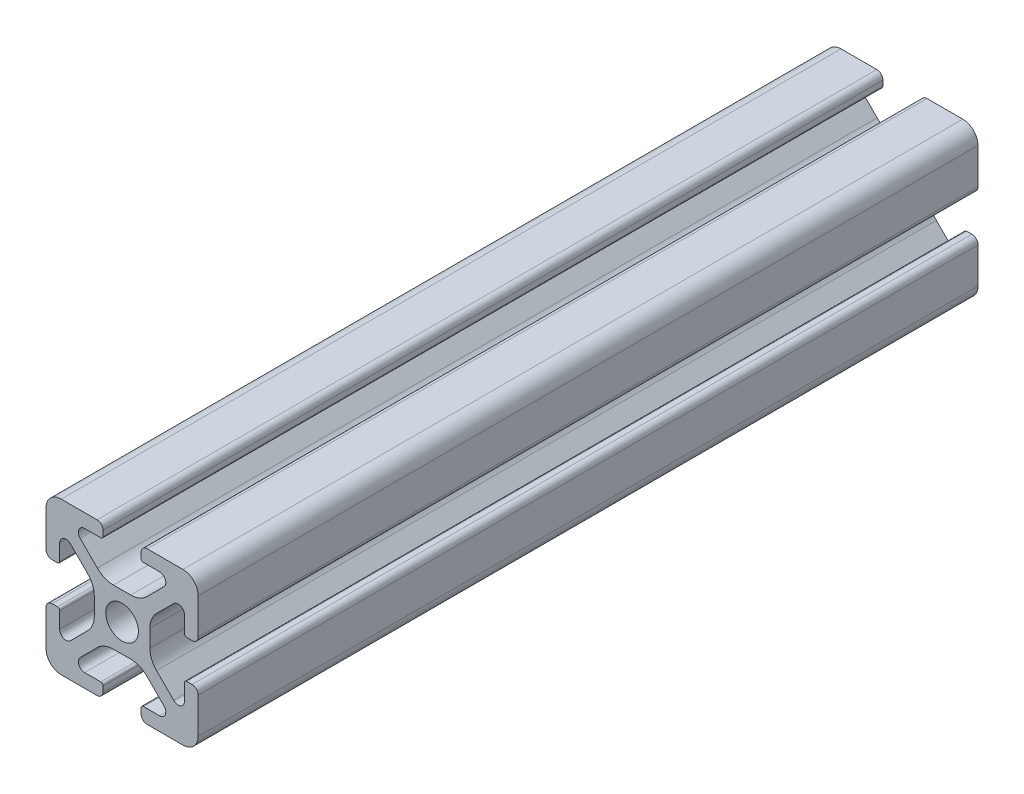
from build123d import *

# Parameters (mm, degrees)
SKIZZE1_R                       = 2.15
AUFSATZ_LINEAR_AUSTRAGEN1_DEPTH = 102.5


with BuildPart() as part:
    # Skizze1 → Aufsatz-Linear austragen1 (new body)
    with BuildSketch(Plane.XY.offset(100)):
        with BuildLine():
            Line((12.499999989, 1.499999999), (12.499999989, 0.800000002))
            ThreePointArc((12.499999989, 0.800000002), (12.734314564, 0.234314576), (13.299999991, 0))
            Line((13.299999991, 0), (18, 0))
            ThreePointArc((18, 0), (19.414213562, 0.585786438), (20, 2))
            Line((20, 2), (20, 6.700000003))
            ThreePointArc((20, 6.700000003), (19.765685425, 7.265685427), (19.2, 7.500000003))
            Line((19.2, 7.500000003), (18.499999995, 7.500000003))
            ThreePointArc((18.499999995, 7.500000003), (18.287867961, 7.412132037), (18.199999995, 7.200000003))
            Line((18.199999995, 7.200000003), (18.199999995, 5.082411607))
            ThreePointArc((18.199999995, 5.082411607), (17.686138517, 4.313363558), (16.778984491, 4.493807713))
            Line((16.778984491, 4.493807713), (14.528679651, 6.744112553))
            ThreePointArc((14.528679651, 6.744112553), (13.878361397, 7.717382599), (13.649999995, 8.865432896))
            Line((13.649999995, 8.865432896), (13.649999995, 11.134567106))
            ThreePointArc((13.649999995, 11.134567106), (13.878361397, 12.282617403), (14.528679651, 13.255887449))
            Line((14.528679651, 13.255887449), (16.778984493, 15.506192291))
            ThreePointArc((16.778984493, 15.506192291), (17.686138518, 15.686636446), (18.199999995, 14.917588398))
            Line((18.199999995, 14.917588398), (18.199999995, 12.800000001))
            ThreePointArc((18.199999995, 12.800000001), (18.287867961, 12.587867966), (18.499999996, 12.5))
            Line((18.499999996, 12.5), (19.199999998, 12.5))
            ThreePointArc((19.199999998, 12.5), (19.765685424, 12.734314576), (20, 13.300000003))
            Line((20, 13.300000003), (20, 18))
            ThreePointArc((20, 18), (19.414213562, 19.414213562), (18, 20))
            Line((18, 20), (13.299999989, 20))
            ThreePointArc((13.299999989, 20), (12.734314564, 19.765685425), (12.499999989, 19.2))
            Line((12.499999989, 19.2), (12.499999989, 18.499999999))
            ThreePointArc((12.499999989, 18.499999999), (12.587867954, 18.287867964), (12.799999989, 18.199999999))
            Line((12.799999989, 18.199999999), (14.917588395, 18.199999999))
            ThreePointArc((14.917588395, 18.199999999), (15.686636445, 17.68613852), (15.50619229, 16.778984493))
            Line((15.50619229, 16.778984493), (13.255887454, 14.528679658))
            ThreePointArc((13.255887454, 14.528679658), (12.282617408, 13.878361404), (11.134567111, 13.650000002))
            Line((11.134567111, 13.650000002), (8.865432888, 13.650000002))
            ThreePointArc((8.865432888, 13.650000002), (7.717382592, 13.878361404), (6.744112546, 14.528679658))
            Line((6.744112546, 14.528679658), (4.493807706, 16.778984498))
            ThreePointArc((4.493807706, 16.778984498), (4.313363551, 17.686138522), (5.082411599, 18.199999999))
            Line((5.082411599, 18.199999999), (7.199999999, 18.199999999))
            ThreePointArc((7.199999999, 18.199999999), (7.412132034, 18.287867965), (7.5, 18.5))
            Line((7.5, 18.5), (7.5, 19.199999998))
            ThreePointArc((7.5, 19.199999998), (7.265685424, 19.765685424), (6.699999997, 20))
            Line((6.699999997, 20), (2, 20))
            ThreePointArc((2, 20), (0.585786438, 19.414213562), (0, 18))
            Line((0, 18), (0, 13.3))
            ThreePointArc((0, 13.3), (0.234314575, 12.734314575), (0.8, 12.5))
            Line((0.8, 12.5), (1.500000004, 12.5))
            ThreePointArc((1.500000004, 12.5), (1.712132038, 12.587867966), (1.800000004, 12.8))
            Line((1.800000004, 12.8), (1.800000004, 14.917588391))
            ThreePointArc((1.800000004, 14.917588391), (2.313861482, 15.68663644), (3.221015508, 15.506192285))
            Line((3.221015508, 15.506192285), (5.471320345, 13.255887449))
            ThreePointArc((5.471320345, 13.255887449), (6.121638599, 12.282617402), (6.350000001, 11.134567106))
            Line((6.350000001, 11.134567106), (6.350000001, 8.865432891))
            ThreePointArc((6.350000001, 8.865432891), (6.121638599, 7.717382594), (5.471320345, 6.744112548))
            Line((5.471320345, 6.744112548), (3.221015505, 4.493807708))
            ThreePointArc((3.221015505, 4.493807708), (2.313861481, 4.313363554), (1.800000004, 5.082411601))
            Line((1.800000004, 5.082411601), (1.800000004, 7.200000001))
            ThreePointArc((1.800000004, 7.200000001), (1.712132038, 7.412132036), (1.500000003, 7.500000002))
            Line((1.500000003, 7.500000002), (0.800000003, 7.500000002))
            ThreePointArc((0.800000003, 7.500000002), (0.234314576, 7.265685427), (0, 6.7))
            Line((0, 6.7), (0, 2))
            ThreePointArc((0, 2), (0.585786438, 0.585786438), (2, 0))
            Line((2, 0), (6.7, 0))
            ThreePointArc((6.7, 0), (7.265685425, 0.234314575), (7.5, 0.8))
            Line((7.5, 0.8), (7.5, 1.5))
            ThreePointArc((7.5, 1.5), (7.412132034, 1.712132034), (7.2, 1.8))
            Line((7.2, 1.8), (5.0824116, 1.8))
            ThreePointArc((5.0824116, 1.8), (4.313363551, 2.313861478), (4.493807706, 3.221015504))
            Line((4.493807706, 3.221015504), (6.744112546, 5.471320344))
            ThreePointArc((6.744112546, 5.471320344), (7.717382592, 6.121638598), (8.865432889, 6.35))
            Line((8.865432889, 6.35), (11.134567106, 6.35))
            ThreePointArc((11.134567106, 6.35), (12.282617403, 6.121638598), (13.255887449, 5.471320344))
            Line((13.255887449, 5.471320344), (15.506192291, 3.221015502))
            ThreePointArc((15.506192291, 3.221015502), (15.686636446, 2.313861477), (14.917588398, 1.8))
            Line((14.917588398, 1.8), (12.79999999, 1.8))
            ThreePointArc((12.79999999, 1.8), (12.587867955, 1.712132034), (12.499999989, 1.499999999))
        make_face()
        with Locations((10, 10)):
            Circle(SKIZZE1_R, mode=Mode.SUBTRACT)
    extrude(amount=-AUFSATZ_LINEAR_AUSTRAGEN1_DEPTH)


solid = part.part
